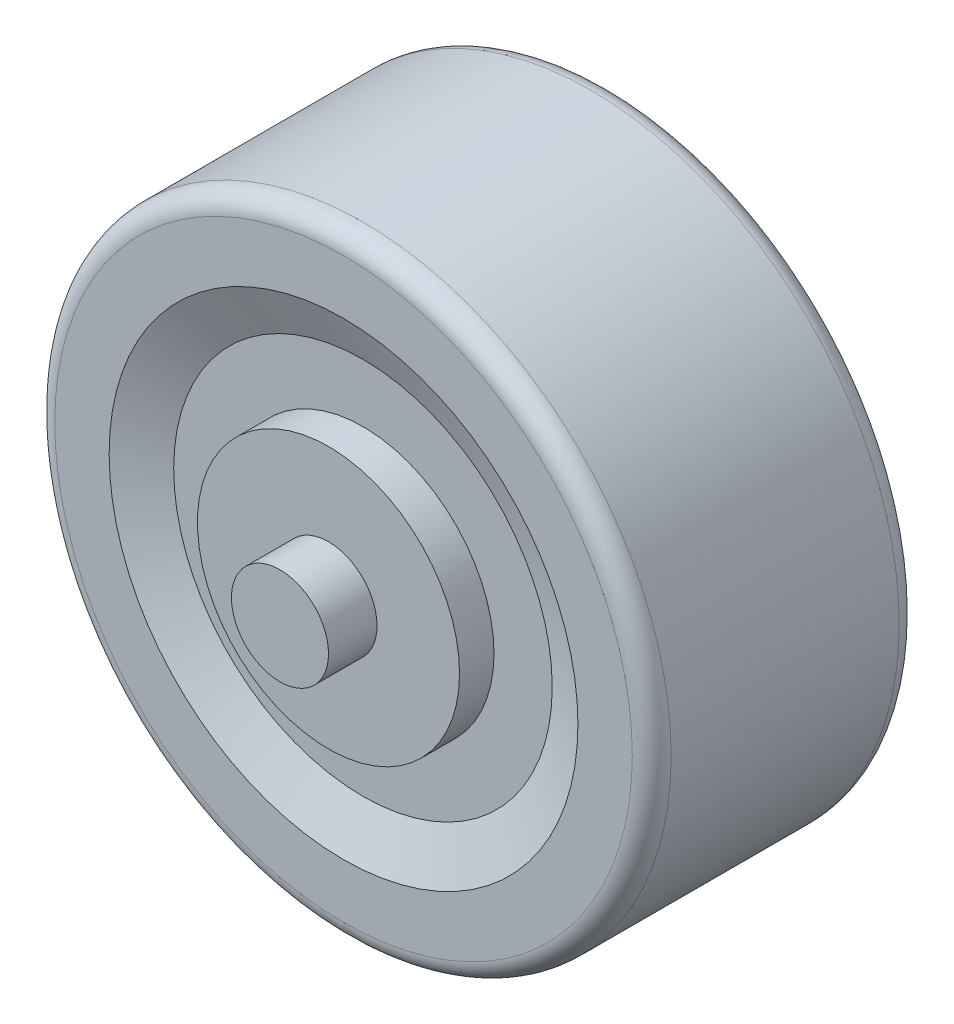
from build123d import *

# Parameters (mm, degrees)
FILLET1_R = 1


with BuildPart() as part:
    # Sketch3 → Revolve1 (revolve)
    with BuildSketch(Plane(origin=(0, 0, 0), x_dir=(1, 0, 0), z_dir=(0, 1, 0))):
        Polygon((6.75, 7.65), (6.75, 5.875), (9.75, 5.875), (12.075, 6.875), (15.875, 6.875), (15.875, 0), (0, 0), (0, 10.15), (2.5, 10.15), (2.5, 7.65), align=None)
    revolve1 = revolve(axis=Axis((0, 0, 0), (0, 0, -1)))

    # Mirror1: Revolve1 across plane
    add(revolve1.mirror(Plane.XY))

    # Fillet1
    fillet1_edges = [part.edges().sort_by_distance(p)[0] for p in [
        (-15.875, 0, -6.875),
        (-15.875, 0, 6.875),
    ]]
    fillet(fillet1_edges, radius=FILLET1_R)


solid = part.part
